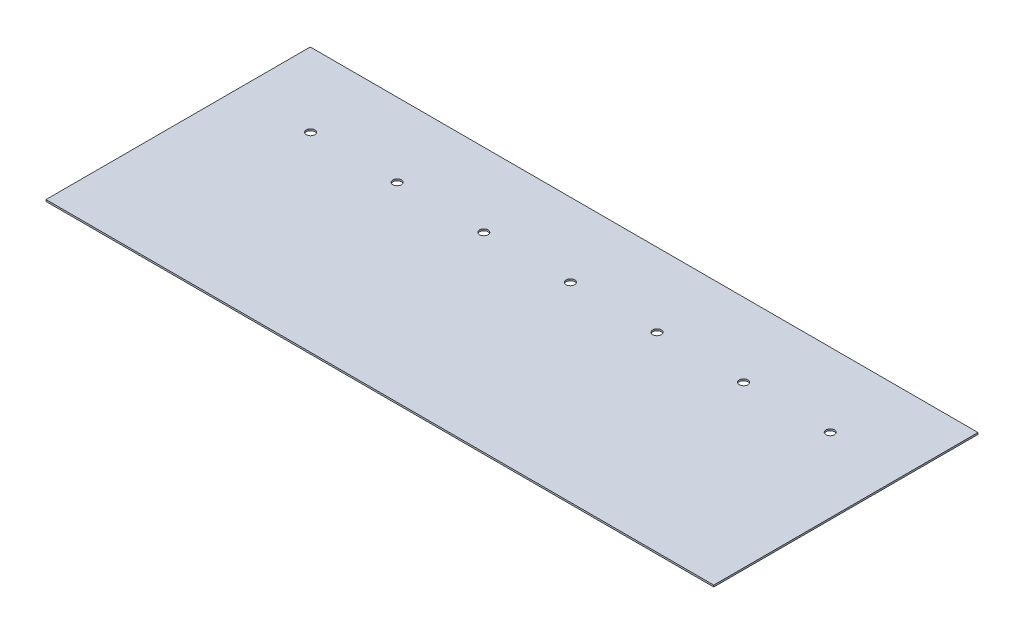
from build123d import *

# Parameters (mm, degrees)
SKETCH1_W               = 391.668
SKETCH1_H               = 199.9996
SKETCH1_R               = 2.5
BOSS_EXTRUDE1_DEPTH     = 1
SKETCH2_W               = 391.668
SKETCH2_H               = 45
CUT_EXTRUDE1_DEPTH      = 1
CUT_EXTRUDE1_DEPTH_BACK = 2


with BuildPart() as part:
    # Sketch1 → Boss-Extrude1 (new body)
    with BuildSketch(Plane(origin=(0, 0, 0), x_dir=(1, 0, 0), z_dir=(0, 1, 0))):
        with Locations((195.834, -99.9998)):
            Rectangle(SKETCH1_W, SKETCH1_H)
        with Locations((348.234, -88.2396)):
            Circle(SKETCH1_R, mode=Mode.SUBTRACT)
        with Locations((297.434, -88.2396)):
            Circle(SKETCH1_R, mode=Mode.SUBTRACT)
        with Locations((246.634, -88.2396)):
            Circle(SKETCH1_R, mode=Mode.SUBTRACT)
        with Locations((43.434, -88.2396)):
            Circle(SKETCH1_R, mode=Mode.SUBTRACT)
        with Locations((94.234, -88.2396)):
            Circle(SKETCH1_R, mode=Mode.SUBTRACT)
        with Locations((145.034, -88.2396)):
            Circle(SKETCH1_R, mode=Mode.SUBTRACT)
        with Locations((195.834, -88.2396)):
            Circle(SKETCH1_R, mode=Mode.SUBTRACT)
    extrude(amount=-BOSS_EXTRUDE1_DEPTH)

    # Sketch2 → Cut-Extrude1 (cut, two sides)
    with BuildSketch(Plane(origin=(0, 0, 0), x_dir=(1, 0, 0), z_dir=(0, 1, 0))) as cut_extrude1_sk:
        with Locations((195.834, -22.5)):
            Rectangle(SKETCH2_W, SKETCH2_H)
    extrude(amount=CUT_EXTRUDE1_DEPTH, mode=Mode.SUBTRACT)
    extrude(cut_extrude1_sk.sketch, amount=-CUT_EXTRUDE1_DEPTH_BACK, mode=Mode.SUBTRACT)


solid = part.part
